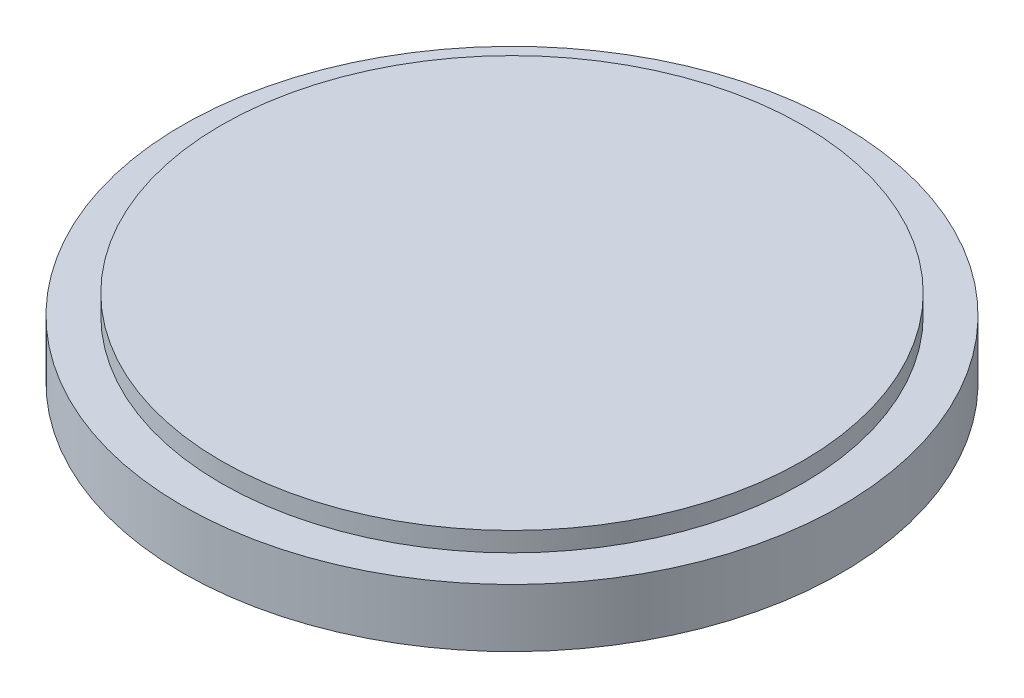
from build123d import *

# Parameters (mm, degrees)
SKETCH1_R           = 75
BOSS_EXTRUDE1_DEPTH = 5
SKETCH2_R           = 85
BOSS_EXTRUDE2_DEPTH = 15


with BuildPart() as part:
    # Sketch1 → Boss-Extrude1 (new body)
    with BuildSketch(Plane(origin=(0, 0, 0), x_dir=(1, 0, 0), z_dir=(0, 1, 0))):
        Circle(SKETCH1_R)
    extrude(amount=BOSS_EXTRUDE1_DEPTH)

    # Sketch2 → Boss-Extrude2 (add)
    with BuildSketch(Plane.XZ):
        Circle(SKETCH2_R)
    extrude(amount=BOSS_EXTRUDE2_DEPTH)


solid = part.part
